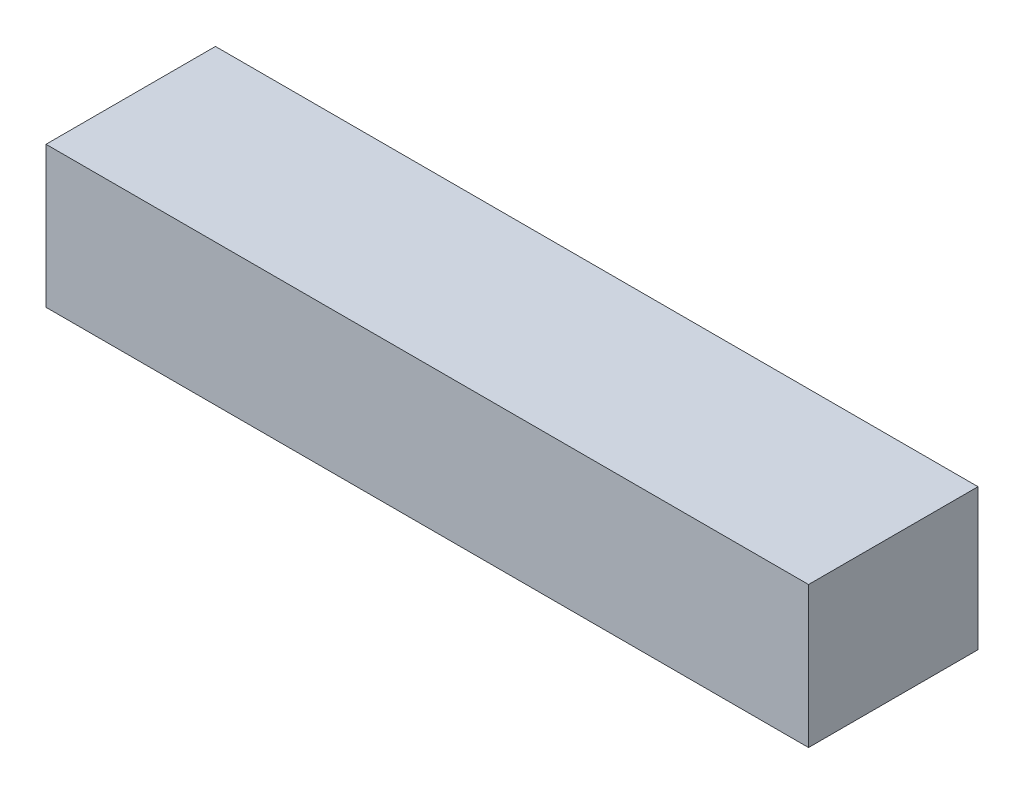
from build123d import *

# Parameters (mm, degrees)
SKETCH_1_W      = 27
SKETCH_1_H      = 6
EXTRUDE_1_DEPTH = 5


with BuildPart() as part:
    # ｽｹｯﾁ1 → ﾎﾞｽ - 押し出し1 (new body)
    with BuildSketch(Plane(origin=(0, 0, 0), x_dir=(1, 0, 0), z_dir=(0, 1, 0))):
        with Locations((13.5, -3)):
            Rectangle(SKETCH_1_W, SKETCH_1_H)
    extrude(amount=EXTRUDE_1_DEPTH)


solid = part.part
